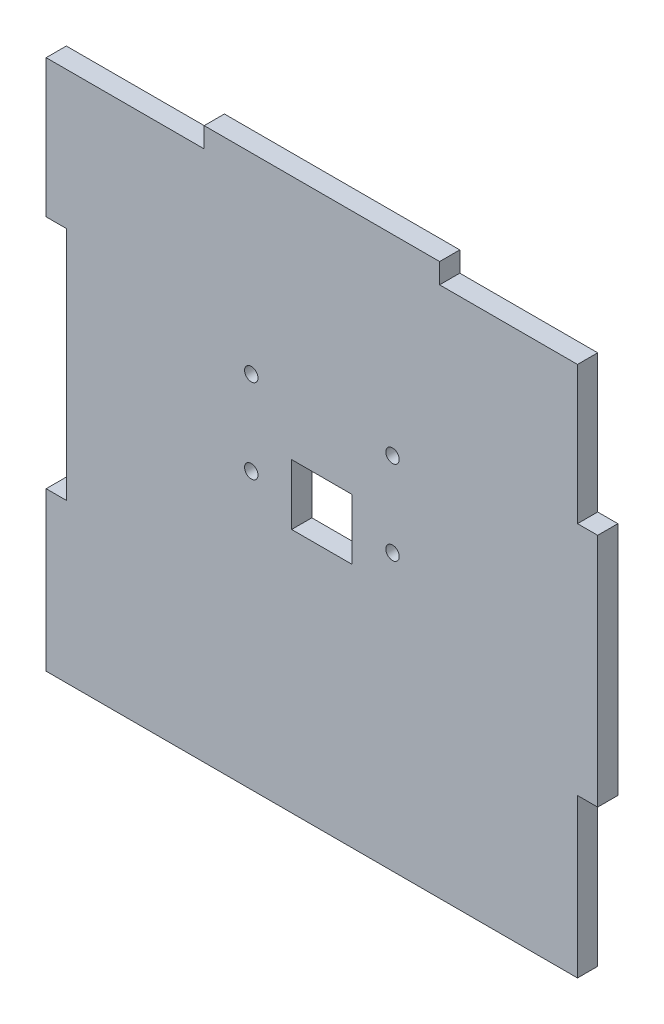
from build123d import *

# Parameters (mm, degrees)
BOSS_EXTRUDE1_DEPTH = 3
SKETCH2_R           = 1
SKETCH2_W           = 9
SKETCH2_H           = 9
CUT_EXTRUDE1_DEPTH  = 3


with BuildPart() as part:
    # Sketch1 → Boss-Extrude1 (new body)
    with BuildSketch(Plane.XY):
        Polygon((-38, 39.5), (-17.5, 39.5), (-17.5, 42.5), (17.5, 42.5), (17.5, 39.5), (38, 39.5), (38, 19), (41, 19), (41, 16), (41, -16), (38, -16), (38, -19), (38, -39.5), (-41, -39.5), (-41, -19), (-41, -16), (-38, -16), (-38, 16), (-38, 19), (-41, 19), (-41, 39.5), align=None)
    extrude(amount=BOSS_EXTRUDE1_DEPTH)

    # Sketch2 → Cut-Extrude1 (cut)
    with BuildSketch(Plane.XY.offset(3)):
        with Locations((-10.5, 14)):
            Circle(SKETCH2_R)
        with Locations((-10.5, 1.5)):
            Circle(SKETCH2_R)
        with Locations((10.5, 1.5)):
            Circle(SKETCH2_R)
        with Locations((10.5, 14)):
            Circle(SKETCH2_R)
        with Locations((0, 1.5)):
            Rectangle(SKETCH2_W, SKETCH2_H)
    extrude(amount=-CUT_EXTRUDE1_DEPTH, mode=Mode.SUBTRACT)


solid = part.part
